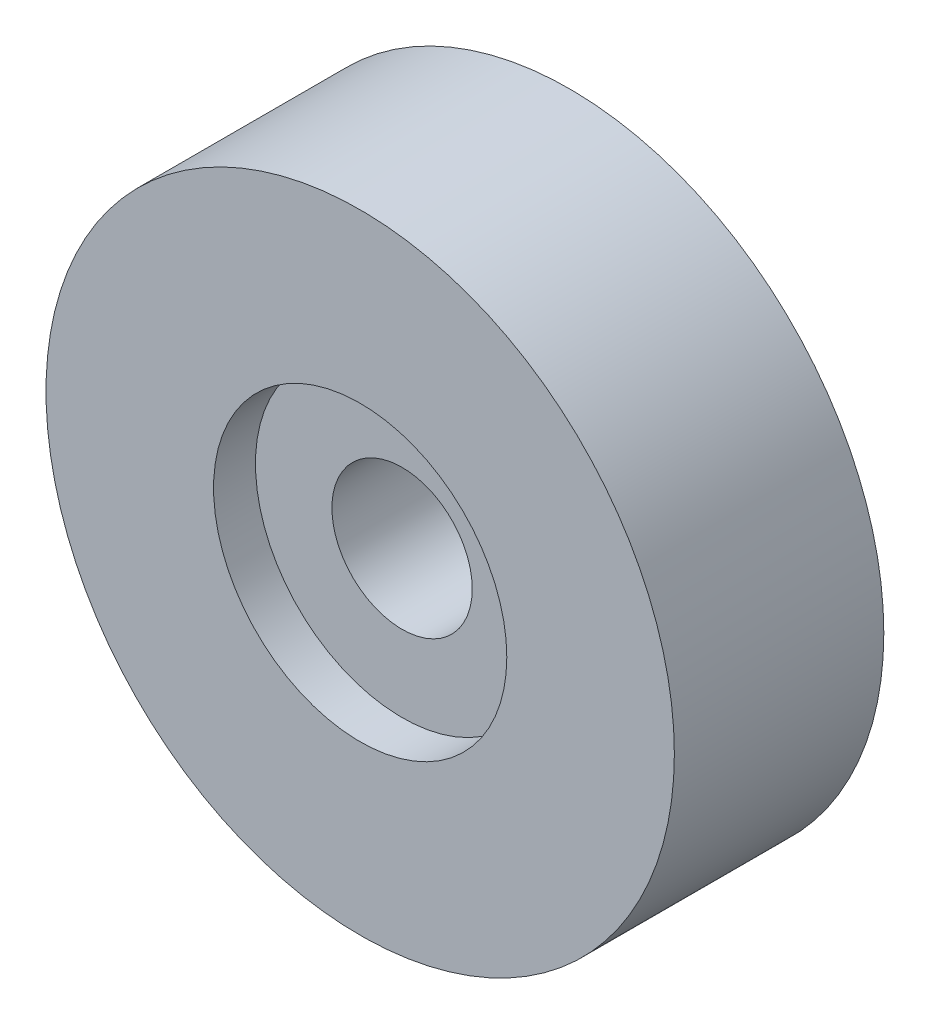
from build123d import *

# Parameters (mm, degrees)
SKIZZE1_R                       = 15
SKIZZE1_R_2                     = 3.35
AUFSATZ_LINEAR_AUSTRAGEN1_DEPTH = 10
SKIZZE2_R                       = 7
SCHNITT_LINEAR_AUSTRAGEN1_DEPTH = 2


with BuildPart() as part:
    # Skizze1 → Aufsatz-Linear austragen1 (new body)
    with BuildSketch(Plane.XY):
        Circle(SKIZZE1_R)
        Circle(SKIZZE1_R_2, mode=Mode.SUBTRACT)
    extrude(amount=AUFSATZ_LINEAR_AUSTRAGEN1_DEPTH)

    # Skizze2 → Schnitt-Linear austragen1 (cut)
    with BuildSketch(Plane.XY.offset(10)):
        Circle(SKIZZE2_R)
    extrude(amount=-SCHNITT_LINEAR_AUSTRAGEN1_DEPTH, mode=Mode.SUBTRACT)


solid = part.part
